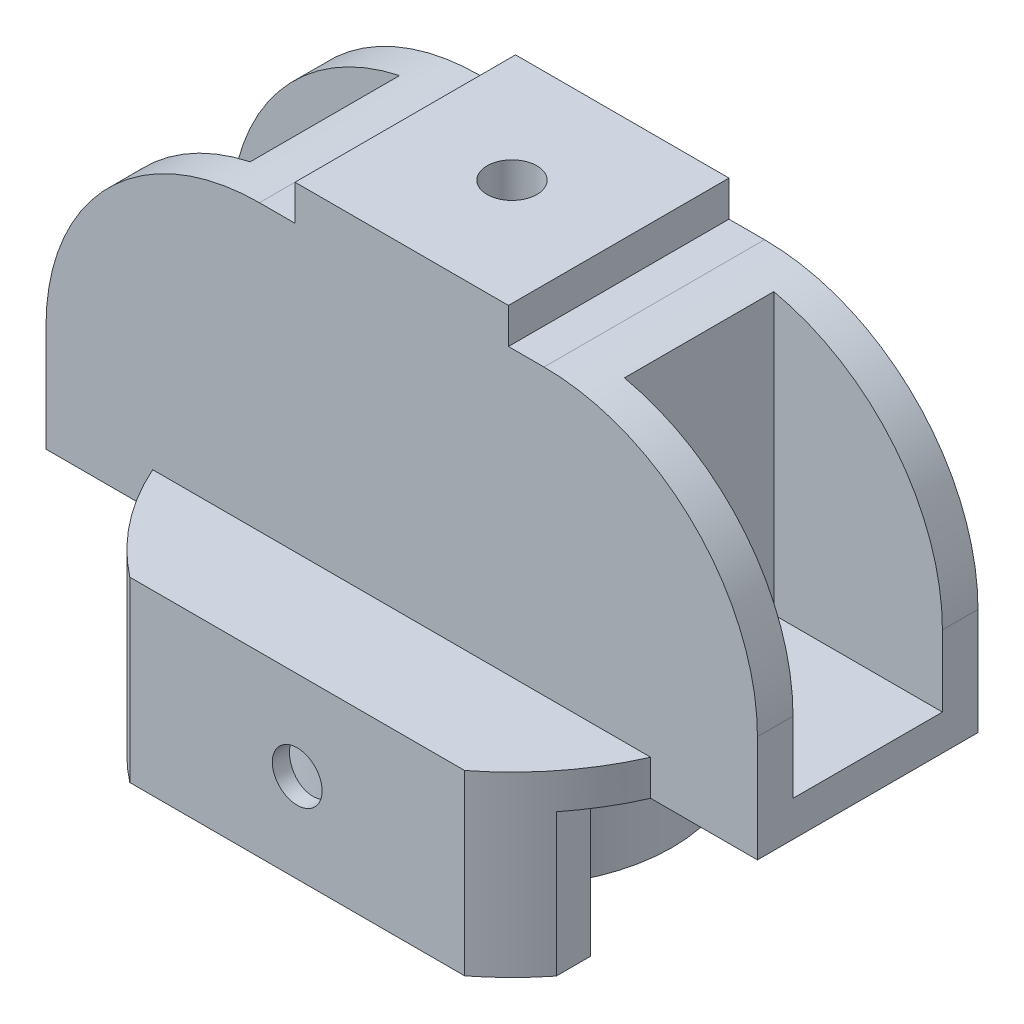
from build123d import *

# Parameters (mm, degrees)
SKETCH1_R               = 22.5
SKETCH1_R_2             = 17.5
BOSS_EXTRUDE1_DEPTH     = 20
BOSS_EXTRUDE5_DEPTH     = 20
BOSS_EXTRUDE5_2_DEPTH   = 20
SKETCH5_W               = 70
SKETCH5_H               = 60.378075934
BOSS_EXTRUDE7_DEPTH     = 5
SKETCH6_W               = 15
SKETCH6_H               = 5
SKETCH6_W_2             = 52.6
SKETCH6_H_2             = 21
BOSS_EXTRUDE8_DEPTH     = 40
SKETCH7_W               = 100
SKETCH7_H               = 31
BOSS_EXTRUDE9_DEPTH     = 5
CUT_EXTRUDE1_DEPTH      = 1
CUT_EXTRUDE1_DEPTH_BACK = 66
FILLET1_R               = 30
SKETCH9_W               = 30
SKETCH9_H               = 31
BOSS_EXTRUDE10_DEPTH    = 5
SKETCH10_R              = 3.5
CUT_EXTRUDE2_DEPTH      = 71
SKETCH11_R              = 12.5
CUT_EXTRUDE3_DEPTH      = 45
SKETCH12_R              = 3.5
CUT_EXTRUDE4_DEPTH      = 61.378075935


with BuildPart() as part:
    # Sketch1 → Boss-Extrude1 (new body)
    with BuildSketch(Plane(origin=(0, 0, 0), x_dir=(1, 0, 0), z_dir=(0, 1, 0))):
        Circle(SKETCH1_R)
        Circle(SKETCH1_R_2, mode=Mode.SUBTRACT)
    extrude(amount=BOSS_EXTRUDE1_DEPTH)



with BuildPart() as body_2:
    # Sketch2 → Boss-Extrude5 (new body)
    with BuildSketch(Plane(origin=(0, 20, 0), x_dir=(1, 0, 0), z_dir=(0, 1, 0))):
        with BuildLine():
            Line((-20.566963801, -19), (-30, -19))
            Line((-30, -19), (-30, -30.189037967))
            Line((-30, -30.189037967), (30, -30.189037967))
            Line((30, -30.189037967), (30, -19))
            Line((30, -19), (20.566963801, -19))
            ThreePointArc((20.566963801, -19), (0, -28), (-20.566963801, -19))
        make_face()
    extrude(amount=-BOSS_EXTRUDE5_DEPTH)


with BuildPart() as body_3:
    # Sketch2 → Boss-Extrude5 2 (new body)
    with BuildSketch(Plane(origin=(0, 20, 0), x_dir=(1, 0, 0), z_dir=(0, 1, 0))):
        with BuildLine():
            Line((-30, 30.189037967), (-30, 19))
            Line((-30, 19), (-20.566963801, 19))
            ThreePointArc((-20.566963801, 19), (0, 28), (20.566963801, 19))
            Line((20.566963801, 19), (30, 19))
            Line((30, 19), (30, 30.189037967))
            Line((30, 30.189037967), (-30, 30.189037967))
        make_face()
    extrude(amount=-BOSS_EXTRUDE5_2_DEPTH)


with BuildPart() as part_1:
    add(part.part)

    add(body_2.part)  # Boss-Extrude7 merges body 2

    add(body_3.part)  # Boss-Extrude7 merges body 3
    # Sketch5 → Boss-Extrude7 (add)
    with BuildSketch(Plane(origin=(0, 20, 0), x_dir=(1, 0, 0), z_dir=(0, 1, 0))):
        Rectangle(SKETCH5_W, SKETCH5_H)
    extrude(amount=BOSS_EXTRUDE7_DEPTH)

    # Sketch6 → Boss-Extrude8 (add)
    with BuildSketch(Plane(origin=(0, 25, 0), x_dir=(1, 0, 0), z_dir=(0, 1, 0))):
        Polygon((26.3, -10.5), (-26.3, -10.5), (-35, -10.5), (-35, -15.5), (35, -15.5), (35, -10.5), align=None)
        with Locations((42.5, -13)):
            Rectangle(SKETCH6_W, SKETCH6_H)
        with Locations((-42.5, -13)):
            Rectangle(SKETCH6_W, SKETCH6_H)
        with Locations((-42.5, 13)):
            Rectangle(SKETCH6_W, SKETCH6_H)
        Polygon((-35, 10.5), (-26.3, 10.5), (26.3, 10.5), (35, 10.5), (35, 15.5), (-35, 15.5), align=None)
        with Locations((42.5, 13)):
            Rectangle(SKETCH6_W, SKETCH6_H)
        Rectangle(SKETCH6_W_2, SKETCH6_H_2)
    extrude(amount=BOSS_EXTRUDE8_DEPTH)

    # Sketch7 → Boss-Extrude9 (add)
    with BuildSketch(Plane.XZ.offset(-25)):
        Rectangle(SKETCH7_W, SKETCH7_H)
    extrude(amount=BOSS_EXTRUDE9_DEPTH)

    # Sketch8 → Cut-Extrude1 (cut, two sides)
    with BuildSketch(Plane.XZ) as cut_extrude1_sk:
        with BuildLine():
            ThreePointArc((48.319407886, 15.5), (0, 50.744607383), (-48.319407886, 15.5))
            Line((-48.319407886, 15.5), (-35, 15.5))
            ThreePointArc((-35, 15.5), (0, 38.278584091), (35, 15.5))
            Line((35, 15.5), (48.319407886, 15.5))
        make_face()
        with BuildLine():
            Line((-35, -15.5), (-48.319407886, -15.5))
            ThreePointArc((-48.319407886, -15.5), (0, -50.744607383), (48.319407886, -15.5))
            Line((48.319407886, -15.5), (35, -15.5))
            ThreePointArc((35, -15.5), (0, -38.278584091), (-35, -15.5))
        make_face()
    extrude(amount=CUT_EXTRUDE1_DEPTH, mode=Mode.SUBTRACT)
    extrude(cut_extrude1_sk.sketch, amount=-CUT_EXTRUDE1_DEPTH_BACK, mode=Mode.SUBTRACT)

    # Fillet1
    fillet1_edges = [part_1.edges().sort_by_distance(p)[0] for p in [
        (-50, 65, -13),
        (50, 65, 13),
    ]]
    fillet(fillet1_edges, radius=FILLET1_R)

    # Sketch9 → Boss-Extrude10 (add)
    with BuildSketch(Plane(origin=(0, 65, 0), x_dir=(1, 0, 0), z_dir=(0, 1, 0))):
        Rectangle(SKETCH9_W, SKETCH9_H)
    extrude(amount=BOSS_EXTRUDE10_DEPTH)

    # Sketch10 → Cut-Extrude2 (cut, through all)
    with BuildSketch(Plane(origin=(0, 70, 0), x_dir=(1, 0, 0), z_dir=(0, 1, 0))):
        Circle(SKETCH10_R)
    extrude(amount=-CUT_EXTRUDE2_DEPTH, mode=Mode.SUBTRACT)

    # Sketch11 → Cut-Extrude3 (cut)
    with BuildSketch(Plane.XZ.offset(-20)):
        Circle(SKETCH11_R)
    extrude(amount=-CUT_EXTRUDE3_DEPTH, mode=Mode.SUBTRACT)

    # Sketch12 → Cut-Extrude4 (cut, through all)
    with BuildSketch(Plane.XY.offset(30.189037967)):
        with Locations((0, 12.5)):
            Circle(SKETCH12_R)
    extrude(amount=-CUT_EXTRUDE4_DEPTH, mode=Mode.SUBTRACT)


solid = part_1.part
